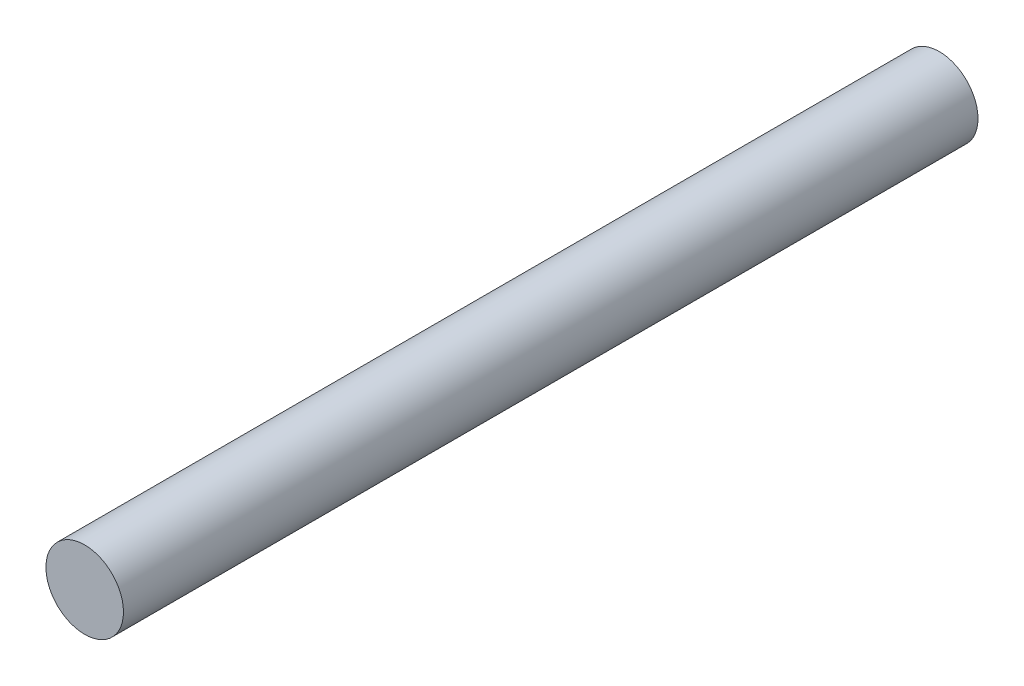
from build123d import *

# Parameters (mm, degrees)
IZIM1_R                     = 0.5
Y_KSEKLIK_EKSTR_ZYON1_DEPTH = 5.51


with BuildPart() as part:
    # Çizim1 → Yükseklik-Ekstrüzyon1 (new body, symmetric)
    with BuildSketch(Plane.XY):
        Circle(IZIM1_R)
    extrude(amount=Y_KSEKLIK_EKSTR_ZYON1_DEPTH, both=True)


solid = part.part
